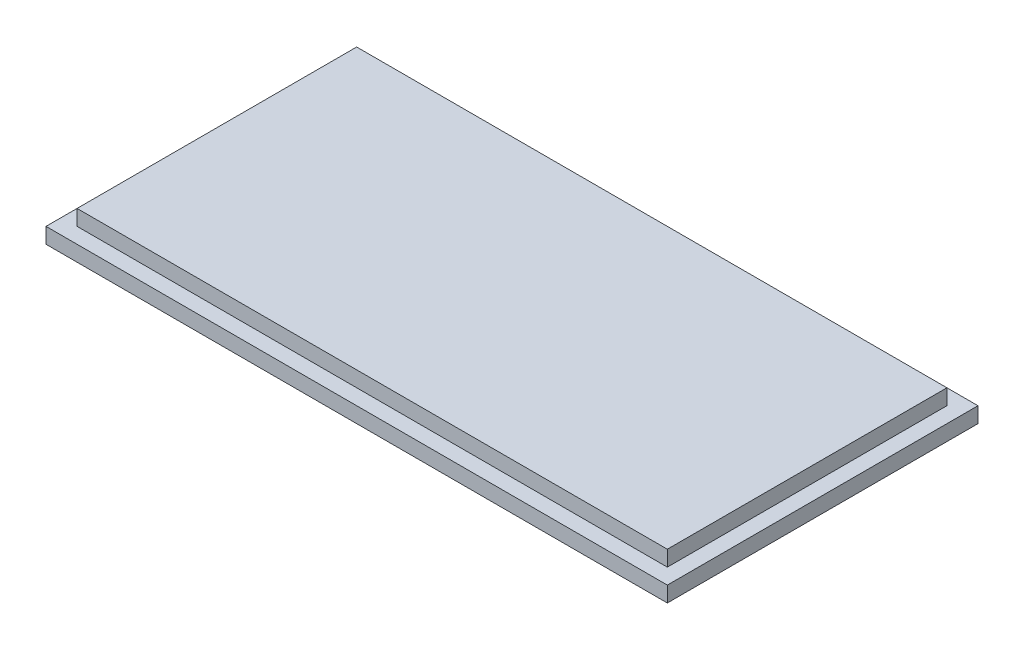
from build123d import *

# Parameters (mm, degrees)
SKETCH1_W           = 200
SKETCH1_H           = 100
BOSS_EXTRUDE1_DEPTH = 5
SKETCH2_W           = 190
SKETCH2_H           = 90
BOSS_EXTRUDE2_DEPTH = 5


with BuildPart() as part:
    # Sketch1 → Boss-Extrude1 (new body)
    with BuildSketch(Plane(origin=(0, 0, 0), x_dir=(1, 0, 0), z_dir=(0, 1, 0))):
        with Locations((100, 50)):
            Rectangle(SKETCH1_W, SKETCH1_H)
    extrude(amount=BOSS_EXTRUDE1_DEPTH)

    # Sketch2 → Boss-Extrude2 (add)
    with BuildSketch(Plane(origin=(0, 5, 0), x_dir=(1, 0, 0), z_dir=(0, 1, 0))):
        with Locations((100, 50)):
            Rectangle(SKETCH2_W, SKETCH2_H)
    extrude(amount=BOSS_EXTRUDE2_DEPTH)


solid = part.part
